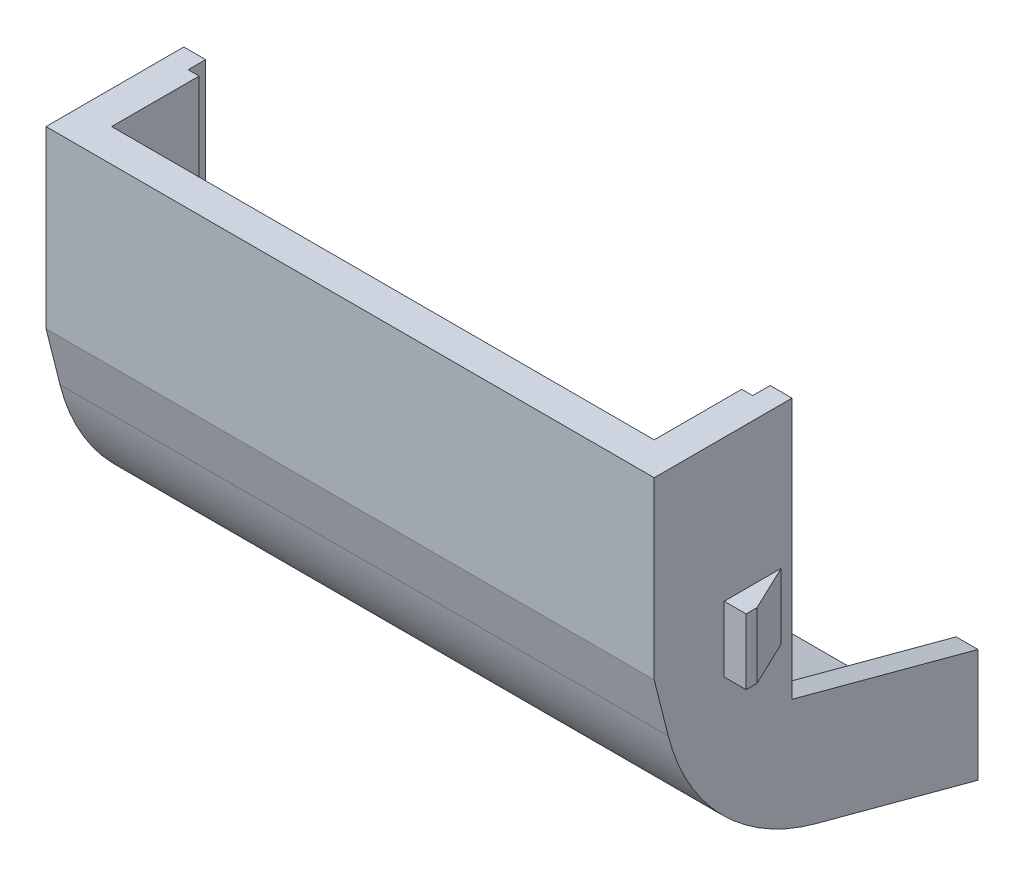
from build123d import *

# Parameters (mm, degrees)
SKETCH_1_W          = 27.8
SKETCH_1_H          = 8
EXTRUDE_1_DEPTH     = 7.8
EXTRUDE_2_DEPTH     = 27.8
SKETCH_4_R          = 1.15
EXTRUDE_3_DEPTH     = 2
CUT_EXTRUDE_4_DEPTH = 24.8
SKETCH_15_W         = 27.8
SKETCH_15_H         = 4.251772847
EXTRUDE_4_DEPTH     = 1.9
FILLET_1_R          = 8
FILLET_2_R          = 9.5
EXTRUDE_5_DEPTH     = 27.8
CUT_EXTRUDE_6_DEPTH = 24.8
CUT_EXTRUDE_7_DEPTH = 40.8
SKETCH_21_W         = 2.6
SKETCH_21_H         = 3
EXTRUDE_6_DEPTH     = 1
CUT_EXTRUDE_8_DEPTH = 3
CUT_EXTRUDE_9_DEPTH = 0.5


with BuildPart() as part:
    # 草图1 → 凸台-拉伸1 (new body)
    with BuildSketch(Plane.XY):
        with Locations((13.9, -4)):
            Rectangle(SKETCH_1_W, SKETCH_1_H)
    extrude(amount=EXTRUDE_1_DEPTH)

    # 草图2 → 凸台-拉伸2 (add)
    with BuildSketch(Plane.ZY):
        Polygon((5.795554958, -15.947085729), (0, -17.5), (0, -8), (7.8, -8), align=None)
    extrude(amount=-EXTRUDE_2_DEPTH)

    # 草图4 → 凸台-拉伸3 (add)
    with BuildSketch(Plane(origin=(0, 0, -1.9), x_dir=(-1, 0, 0), z_dir=(0, 0, -1))):
        with BuildLine():
            Line((0, -2), (0, -4.7))
            Line((0, -4.7), (6, -4.7))
            ThreePointArc((6, -4.7), (6.353553391, -4.553553391), (6.5, -4.2))
            Line((6.5, -4.2), (6.5, -2))
            Line((6.5, -2), (6.5, 2.4))
            ThreePointArc((6.5, 2.4), (6.353553391, 2.753553391), (6, 2.9))
            Line((6, 2.9), (4, 2.9))
            ThreePointArc((4, 2.9), (2.232233047, 2.167766953), (1.5, 0.4))
            Line((1.5, 0.4), (1.5, -1.5))
            ThreePointArc((1.5, -1.5), (1.353553391, -1.853553391), (1, -2))
            Line((1, -2), (0, -2))
        make_face()
        with Locations((3.6, 0.5)):
            Circle(SKETCH_4_R, mode=Mode.SUBTRACT)
    extrude_3 = extrude(amount=-EXTRUDE_3_DEPTH)

    # 镜向1: 凸台-拉伸3 across plane
    add(extrude_3.mirror(Plane.ZY.offset(-13.9)))

    # 草图13 → 切除-拉伸4 (cut)
    with BuildSketch(Plane.ZY.offset(-1.5)):
        Polygon((1.5, 0), (1.5, -11.921695309), (0, -12.323619098), (0, -15.947085729), (4.556522218, -14.726169281), (6.3, -7.813748582), (6.3, 0), align=None)
    extrude(amount=-CUT_EXTRUDE_4_DEPTH, mode=Mode.SUBTRACT)

    # 草图15 → 凸台-拉伸4 (add)
    with BuildSketch(Plane(origin=(0, 0, 0), x_dir=(-1, 0, 0), z_dir=(0, 0, -1))):
        with Locations((-13.9, -4.125886424)):
            Rectangle(SKETCH_15_W, SKETCH_15_H)
    extrude(amount=EXTRUDE_4_DEPTH)

    # 圆角1
    fillet_1_edges = [part.edges().sort_by_distance(p)[0] for p in [
        (13.9, -14.726169281, 4.556522218),
    ]]
    fillet(fillet_1_edges, radius=FILLET_1_R)

    # 圆角2
    fillet_2_edges = [part.edges().sort_by_distance(p)[0] for p in [
        (13.9, -15.947085729, 5.795554958),
    ]]
    fillet(fillet_2_edges, radius=FILLET_2_R)

    # 草图17 → 凸台-拉伸5 (add)
    with BuildSketch(Plane(origin=(27.8, 0, 0), x_dir=(0, 0, -1), z_dir=(1, 0, 0))):
        Polygon((0, -17.5), (7, -19.375644347), (7, -12.646349174), (0, -10.770704827), align=None)
    extrude(amount=-EXTRUDE_5_DEPTH)

    # 草图18 → 切除-拉伸6 (cut)
    with BuildSketch(Plane.ZY.offset(-26.3)):
        Polygon((0, -12.323619098), (0, -15.947085729), (-7, -17.822730076), (-7, -14.199263445), align=None)
    extrude(amount=CUT_EXTRUDE_6_DEPTH, mode=Mode.SUBTRACT)

    # 草图19 → 切除-拉伸7 (cut)
    with BuildSketch(Plane(origin=(34.3, 0, 0), x_dir=(0, 0, -1), z_dir=(1, 0, 0))):
        Polygon((7, 2.9), (7, -14.199263445), (-1.5, -11.921695309), (-1.5, 2.9), align=None)
    extrude(amount=-CUT_EXTRUDE_7_DEPTH, mode=Mode.SUBTRACT)

    # 草图21 → 凸台-拉伸6 (add)
    with BuildSketch(Plane.ZY):
        with Locations((3.3, -7.99)):
            Rectangle(SKETCH_21_W, SKETCH_21_H)
    extrude_6 = extrude(amount=EXTRUDE_6_DEPTH)

    # 草图22 → 切除-拉伸8 (cut)
    with BuildSketch(Plane(origin=(0, -9.49, 0), x_dir=(-1, 0, 0), z_dir=(0, -1, 0))):
        Polygon((0, -2), (1, -4.1), (1, -2), align=None)
    cut_extrude_8 = extrude(amount=-CUT_EXTRUDE_8_DEPTH, mode=Mode.SUBTRACT)

    # 镜向5: 凸台-拉伸6, 切除-拉伸8 across plane
    add(extrude_6.mirror(Plane.ZY.offset(-13.9)))
    add(cut_extrude_8.mirror(Plane.ZY.offset(-13.9)), mode=Mode.SUBTRACT)

    # 草图23 → 切除-拉伸9 (cut)
    with BuildSketch(Plane.ZY.offset(-26.3)):
        Polygon((2.3, -12.5355569), (-7, -15.027484389), (-7, -14.199263445), (1.5, -11.921695309), (1.5, 0), (2.3, 0), align=None)
    cut_extrude_9 = extrude(amount=-CUT_EXTRUDE_9_DEPTH, mode=Mode.SUBTRACT)

    # 镜向6: 切除-拉伸9 across plane
    add(cut_extrude_9.mirror(Plane.ZY.offset(-13.9)), mode=Mode.SUBTRACT)


solid = part.part
